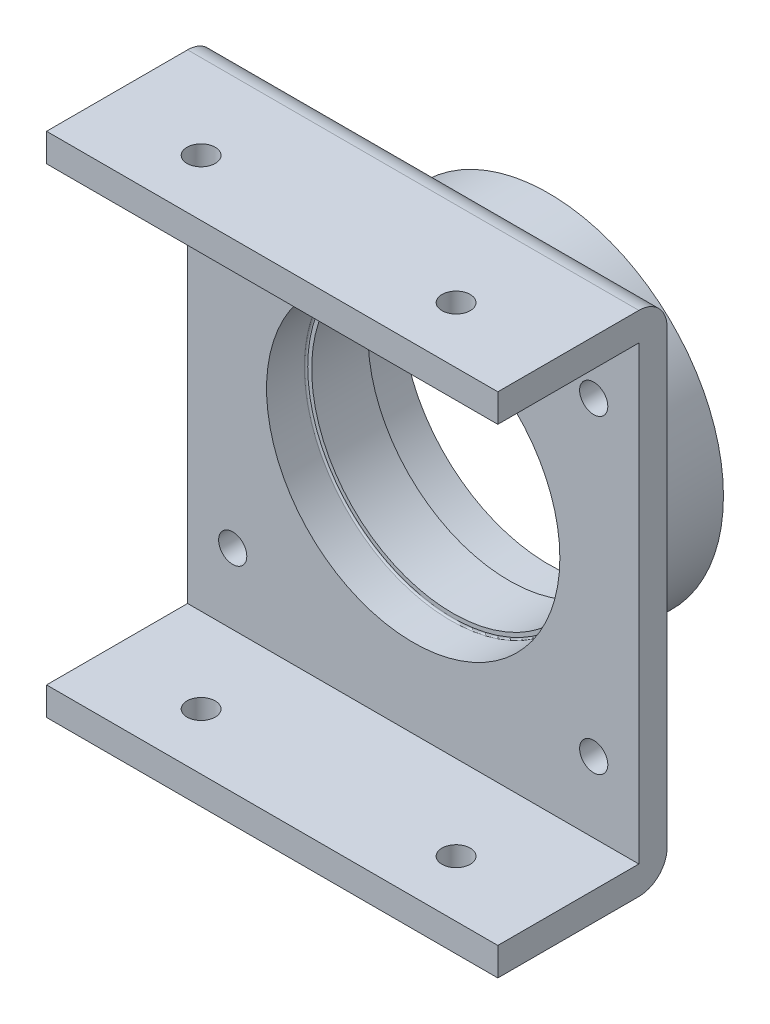
from build123d import *

# Parameters (mm, degrees)
SKETCH1_R             = 31
SKETCH1_R_2           = 26
BOSS_EXTRUDE1_DEPTH   = 7
SKETCH2_R             = 31
SKETCH2_R_2           = 25
BOSS_EXTRUDE3_DEPTH   = 10
SKETCH3_R             = 31
SKETCH3_R_2           = 26
BOSS_EXTRUDE4_DEPTH   = 7
FILLET1_R             = 0.3
SKETCH4_W             = 80
SKETCH4_H             = 80
SKETCH4_R             = 31
BOSS_EXTRUDE5_DEPTH   = 5
FILLET2_R             = 2
M6X1_0_TAPPED_HOLE1_D = 5
SKETCH7_W             = 10
SKETCH7_H             = 5
BOSS_EXTRUDE6_DEPTH   = 80
FILLET3_R             = 5
SKETCH8_W             = 20
SKETCH8_H             = 5
BOSS_EXTRUDE7_DEPTH   = 80
M6X1_0_TAPPED_HOLE2_D = 5


with BuildPart() as part:
    # Sketch1 → Boss-Extrude1 (new body)
    with BuildSketch(Plane.XY):
        Circle(SKETCH1_R)
        Circle(SKETCH1_R_2, mode=Mode.SUBTRACT)
    extrude(amount=BOSS_EXTRUDE1_DEPTH)

    # Sketch2 → Boss-Extrude3 (add)
    with BuildSketch(Plane.XY.offset(7)):
        Circle(SKETCH2_R)
        Circle(SKETCH2_R_2, mode=Mode.SUBTRACT)
    extrude(amount=BOSS_EXTRUDE3_DEPTH)

    # Sketch3 → Boss-Extrude4 (add)
    with BuildSketch(Plane.XY.offset(17)):
        Circle(SKETCH3_R)
        Circle(SKETCH3_R_2, mode=Mode.SUBTRACT)
    extrude(amount=BOSS_EXTRUDE4_DEPTH)

    # Fillet1
    fillet1_edges = [part.edges().sort_by_distance(p)[0] for p in [
        (-26, 0, 7),
        (-26, 0, 17),
    ]]
    fillet(fillet1_edges, radius=FILLET1_R)

    # Sketch4 → Boss-Extrude5 (add)
    with BuildSketch(Plane.XY.offset(24)):
        Rectangle(SKETCH4_W, SKETCH4_H)
        Circle(SKETCH4_R, mode=Mode.SUBTRACT)
    extrude(amount=-BOSS_EXTRUDE5_DEPTH)

    # Fillet2
    fillet2_edges = [part.edges().sort_by_distance(p)[0] for p in [
        (-31, 0, 19),
    ]]
    fillet(fillet2_edges, radius=FILLET2_R)

    # M6x1.0 Tapped Hole1 (through all)
    with Locations(Plane.XY.offset(24)):
        with Locations((-32, 27.5), (32, 27.5), (32, -27.5), (-32, -27.5)):
            Hole(M6X1_0_TAPPED_HOLE1_D / 2)

    # Sketch7 → Boss-Extrude6 (add)
    with BuildSketch(Plane(origin=(40, 0, 0), x_dir=(0, 0, -1), z_dir=(1, 0, 0))):
        with Locations((-24, 42.5)):
            Rectangle(SKETCH7_W, SKETCH7_H)
        with Locations((-24, -42.5)):
            Rectangle(SKETCH7_W, SKETCH7_H)
    extrude(amount=-BOSS_EXTRUDE6_DEPTH)

    # Fillet3
    fillet3_edges = [part.edges().sort_by_distance(p)[0] for p in [
        (0, 45, 19),
        (0, -45, 19),
    ]]
    fillet(fillet3_edges, radius=FILLET3_R)

    # Sketch8 → Boss-Extrude7 (add)
    with BuildSketch(Plane(origin=(40, 0, 0), x_dir=(0, 0, -1), z_dir=(1, 0, 0))):
        with Locations((-39, 42.5)):
            Rectangle(SKETCH8_W, SKETCH8_H)
        with Locations((-39, -42.5)):
            Rectangle(SKETCH8_W, SKETCH8_H)
    extrude(amount=-BOSS_EXTRUDE7_DEPTH)

    # M6x1.0 Tapped Hole2 (through all)
    with Locations(Plane(origin=(0, 45, 0), x_dir=(1, 0, 0), z_dir=(0, 1, 0))):
        with Locations((-22.6, -39), (22.6, -39)):
            Hole(M6X1_0_TAPPED_HOLE2_D / 2)


solid = part.part
